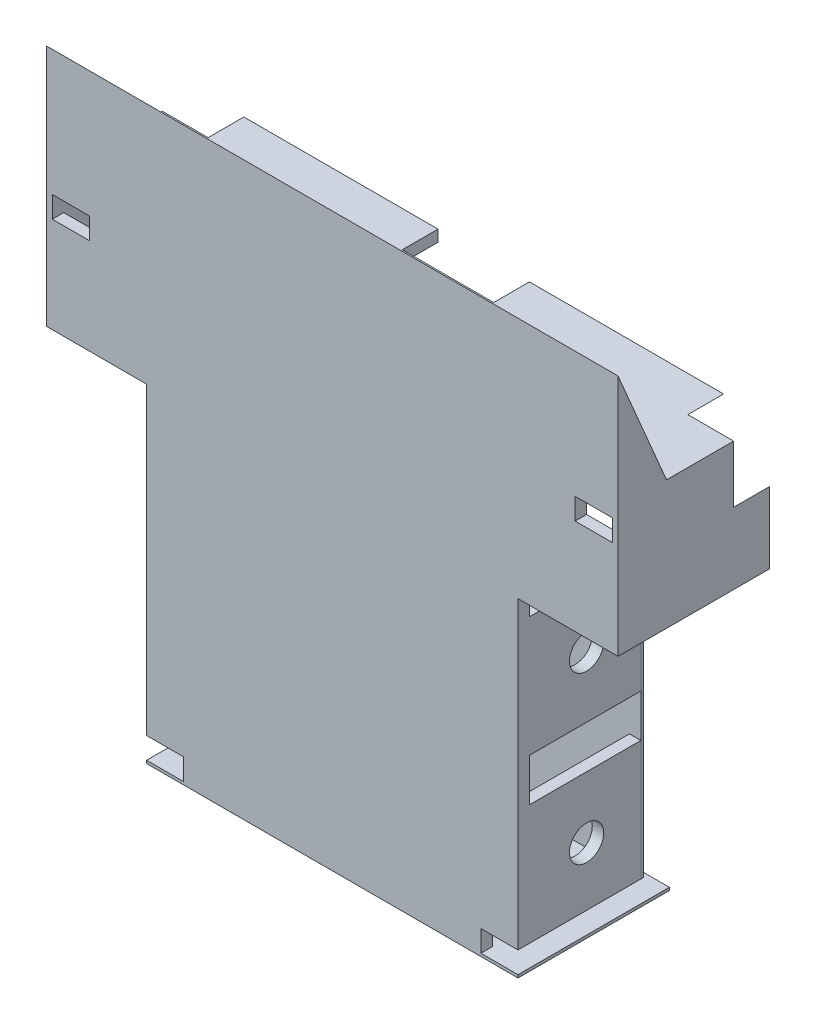
from build123d import *

# Parameters (mm, degrees)
BOSS_EXTRUDE1_DEPTH     = 4
BOSS_EXTRUDE2_DEPTH     = 53
BOSS_EXTRUDE4_DEPTH     = 200
SKETCH5_W               = 25.514718625
SKETCH5_H               = 12.5
CUT_EXTRUDE1_DEPTH      = 20
SKETCH6_W               = 12.5
SKETCH6_H               = 25.514718626
CUT_EXTRUDE2_DEPTH      = 20
SKETCH7_W               = 32
SKETCH7_H               = 12.5
CUT_EXTRUDE3_DEPTH      = 8
CUT_EXTRUDE3_DEPTH_BACK = 6.482
BOSS_EXTRUDE5_DEPTH     = 4
SKETCH9_W               = 4
SKETCH9_H               = 99
BOSS_EXTRUDE6_DEPTH     = 39
SKETCH10_W              = 39
SKETCH10_H              = 15
CUT_EXTRUDE5_DEPTH      = 137
SKETCH12_W              = 35
SKETCH12_H              = 53
CUT_EXTRUDE6_DEPTH      = 8
SKETCH13_R              = 6
CUT_EXTRUDE7_DEPTH      = 135
SKETCH15_W              = 129.449663631
SKETCH15_H              = 99
BOSS_EXTRUDE7_DEPTH     = 1
SPLIT1_SURFACE_1_BACK   = 288.766
SPLIT1_SURFACE_1_DEPTH  = 577.532
SPLIT1_SURFACE_2_BACK   = 288.766
SPLIT1_SURFACE_2_DEPTH  = 577.532
SKETCH17_W              = 13
SKETCH17_H              = 7.5
CUT_EXTRUDE8_DEPTH      = 10


with BuildPart() as part:
    # Sketch1 → Boss-Extrude1 (new body)
    with BuildSketch(Plane.XY):
        Polygon((175.95836944, 160), (24.04163056, 160), (0, 135.95836944), (0, 115), (35, 115), (35, 60), (35, 55), (35, 0), (165, 0), (165, 55), (165, 60), (165, 115), (200, 115), (200, 135.95836944), align=None)
    extrude(amount=BOSS_EXTRUDE1_DEPTH)

    # Sketch3 → Boss-Extrude2 (add)
    with BuildSketch(Plane.XY.offset(4)):
        Polygon((0, 0), (200, 0), (200, 1), (199, 1), (1, 1), (0, 1), align=None)
        Polygon((0, 160), (200, 160), (200, 115), (198, 115), (198, 156), (2, 156), (2, 115), (0, 115), align=None)
    extrude(amount=-BOSS_EXTRUDE2_DEPTH)

    # Sketch4 → Boss-Extrude4 (add)
    with BuildSketch(Plane(origin=(200, 0, 0), x_dir=(0, 0, -1), z_dir=(1, 0, 0))):
        Polygon((-4, 160), (-4, 200), (12.978992648, 160), align=None)
    extrude(amount=-BOSS_EXTRUDE4_DEPTH)

    # Sketch5 → Cut-Extrude1 (cut)
    with BuildSketch(Plane(origin=(-67.97918472, 67.97918472, 0), x_dir=(0.7071067811865505, 0.7071067811865447, 0), z_dir=(-0.7071067811865447, 0.7071067811865505, 0))):
        with Locations((111.722871428, 42.75)):
            Rectangle(SKETCH5_W, SKETCH5_H)
    extrude(amount=CUT_EXTRUDE1_DEPTH, mode=Mode.SUBTRACT)

    # Sketch6 → Cut-Extrude2 (cut)
    with BuildSketch(Plane(origin=(167.97918472, 167.97918472, 0), x_dir=(0, 0, -1), z_dir=(0.7071067811865493, 0.7071067811865458, 0))):
        with Locations((42.75, -29.69848481)):
            Rectangle(SKETCH6_W, SKETCH6_H)
    extrude(amount=CUT_EXTRUDE2_DEPTH, mode=Mode.SUBTRACT)

    # Sketch7 → Cut-Extrude3 (cut, two sides)
    with BuildSketch(Plane(origin=(0, 155, 0), x_dir=(1, 0, 0), z_dir=(0, 1, 0))) as cut_extrude3_sk:
        with Locations((100, 42.75)):
            Rectangle(SKETCH7_W, SKETCH7_H)
    extrude(amount=CUT_EXTRUDE3_DEPTH, mode=Mode.SUBTRACT)
    extrude(cut_extrude3_sk.sketch, amount=-CUT_EXTRUDE3_DEPTH_BACK, mode=Mode.SUBTRACT)

    # Sketch8 → Boss-Extrude5 (add)
    with BuildSketch(Plane.XY.offset(4)):
        Polygon((20.04163056, 156), (2, 156), (2, 137.95836944), align=None)
        Polygon((179.95836944, 156), (198, 156), (198, 137.95836944), align=None)
    extrude(amount=-BOSS_EXTRUDE5_DEPTH)

    # Sketch9 → Boss-Extrude6 (add)
    with BuildSketch(Plane(origin=(0, 0, 0), x_dir=(-1, 0, 0), z_dir=(0, 0, -1))):
        with Locations((-37.550336369, 58)):
            Rectangle(SKETCH9_W, SKETCH9_H)
        with Locations((-163, 58)):
            Rectangle(SKETCH9_W, SKETCH9_H)
    extrude(amount=BOSS_EXTRUDE6_DEPTH)

    # Sketch10 → Cut-Extrude5 (cut)
    with BuildSketch(Plane(origin=(165, 0, 0), x_dir=(0, 0, -1), z_dir=(1, 0, 0))):
        with Locations((19.5, 58)):
            Rectangle(SKETCH10_W, SKETCH10_H)
    extrude(amount=-CUT_EXTRUDE5_DEPTH, mode=Mode.SUBTRACT)

    # Sketch12 → Cut-Extrude6 (cut)
    with BuildSketch(Plane(origin=(0, 1, 0), x_dir=(1, 0, 0), z_dir=(0, 1, 0))):
        with Locations((17.5, 22.5)):
            Rectangle(SKETCH12_W, SKETCH12_H)
        with Locations((182.5, 22.5)):
            Rectangle(SKETCH12_W, SKETCH12_H)
    extrude(amount=-CUT_EXTRUDE6_DEPTH, mode=Mode.SUBTRACT)

    # Sketch13 → Cut-Extrude7 (cut)
    with BuildSketch(Plane(origin=(165, 0, 0), x_dir=(0, 0, -1), z_dir=(1, 0, 0))):
        with Locations((20, 87)):
            Circle(SKETCH13_R)
        with Locations((20, 29)):
            Circle(SKETCH13_R)
    extrude(amount=-CUT_EXTRUDE7_DEPTH, mode=Mode.SUBTRACT)

    # Sketch15 → Boss-Extrude7 (add)
    with BuildSketch(Plane(origin=(0, 0, -39), x_dir=(-1, 0, 0), z_dir=(0, 0, -1))):
        with Locations((-100.275168185, 58)):
            Rectangle(SKETCH15_W, SKETCH15_H)
    extrude(amount=BOSS_EXTRUDE7_DEPTH)


with BuildPart() as body_2:
    # Split1: the piece behind the surface
    add(part.part)
    # Split1 surface: a surface, the sketch's curves swept straight by 577.532 mm
    with BuildLine(Plane(origin=(165, 0, 0), x_dir=(0, 0, -1), z_dir=(1, 0, 0)).offset(-SPLIT1_SURFACE_1_BACK), mode=Mode.PRIVATE) as split1_surface_1_path:
        Line((39, 107.5), (39, 8.5))
    split1_surface_1 = Shell.extrude(split1_surface_1_path.wire(), (1 * SPLIT1_SURFACE_1_DEPTH, 0 * SPLIT1_SURFACE_1_DEPTH, 0 * SPLIT1_SURFACE_1_DEPTH))
    split(bisect_by=split1_surface_1, keep=Keep.BOTTOM)

    # Sketch17 → Cut-Extrude8 (cut)
    with BuildSketch(Plane(origin=(0, 0, 0), x_dir=(-1, 0, 0), z_dir=(0, 0, -1))):
        with Locations((-191.5, 152.25)):
            Rectangle(SKETCH17_W, SKETCH17_H)
        with Locations((-8.5, 152.25)):
            Rectangle(SKETCH17_W, SKETCH17_H)
        with Locations((-158.5, 4.75)):
            Rectangle(SKETCH17_W, SKETCH17_H)
        with Locations((-41.5, 4.75)):
            Rectangle(SKETCH17_W, SKETCH17_H)
    extrude(amount=-CUT_EXTRUDE8_DEPTH, mode=Mode.SUBTRACT)


with BuildPart() as part_1:
    add(part.part)

    # Split1: split by a surface, the side it looks to stays
    # Split1 surface: a surface, the sketch's curves swept straight by 577.532 mm
    with BuildLine(Plane(origin=(165, 0, 0), x_dir=(0, 0, -1), z_dir=(1, 0, 0)).offset(-SPLIT1_SURFACE_2_BACK), mode=Mode.PRIVATE) as split1_surface_2_path:
        Line((39, 107.5), (39, 8.5))
    split1_surface_2 = Shell.extrude(split1_surface_2_path.wire(), (1 * SPLIT1_SURFACE_2_DEPTH, 0 * SPLIT1_SURFACE_2_DEPTH, 0 * SPLIT1_SURFACE_2_DEPTH))
    split(bisect_by=split1_surface_2, keep=Keep.TOP)


solid = Compound([body_2.part, part_1.part])
